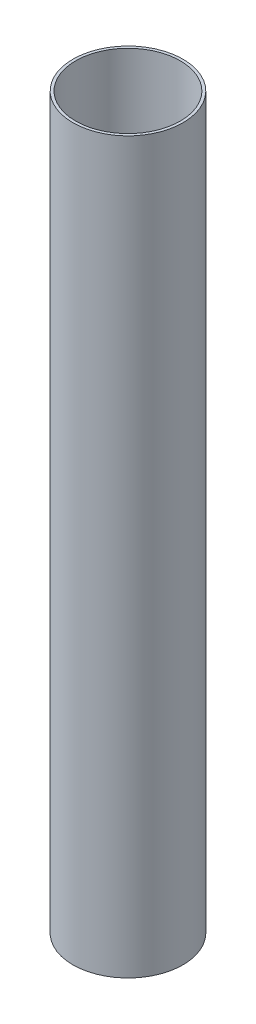
from build123d import *

# Parameters (mm, degrees)
ESQUISSE1_R        = 20
ESQUISSE1_R_2      = 19
BOSS_EXTRU_1_DEPTH = 265


with BuildPart() as part:
    # Esquisse1 → Boss.-Extru.1 (new body)
    with BuildSketch(Plane(origin=(0, 0, 0), x_dir=(1, 0, 0), z_dir=(0, 1, 0))):
        with Locations(Location((0, 0, 0), (0, 0, 270))):  # turned: the seam where the file's is
            Circle(ESQUISSE1_R)
        with Locations(Location((0, 0, 0), (0, 0, 270))):  # turned: the seam where the file's is
            Circle(ESQUISSE1_R_2, mode=Mode.SUBTRACT)
    extrude(amount=BOSS_EXTRU_1_DEPTH)


solid = part.part
